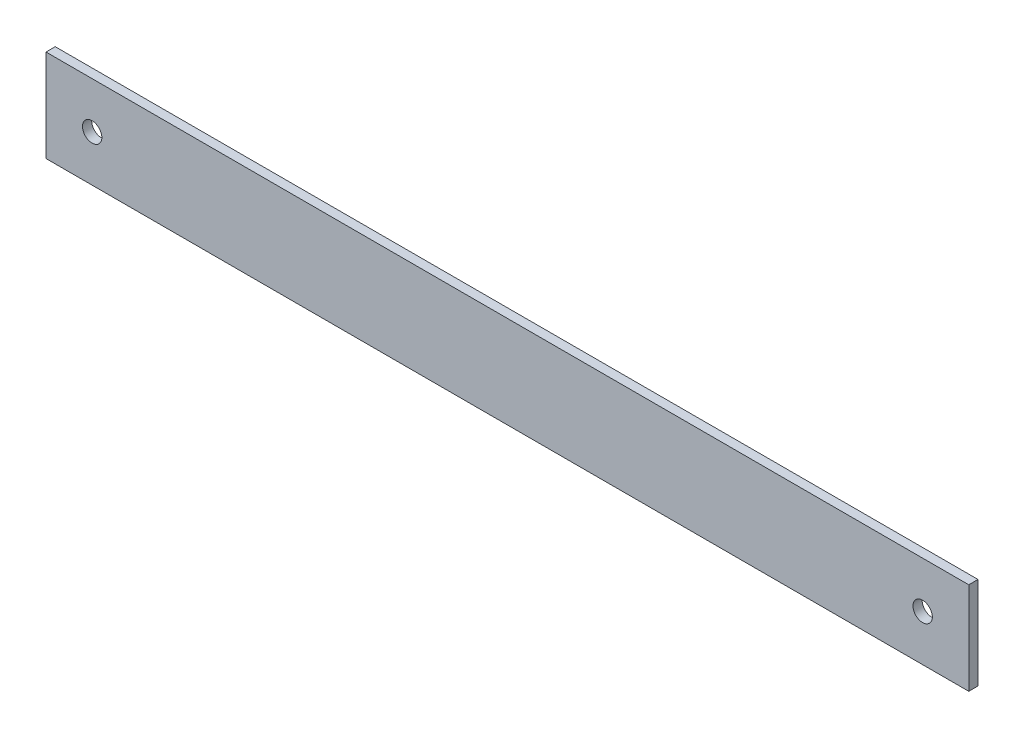
from build123d import *

# Parameters (mm, degrees)
SKETCH_1_W          = 1000
SKETCH_1_H          = 100
EXTRUDE_1_DEPTH     = 5
HOLE_WIZARD_M24_1_D = 21


with BuildPart() as part:
    # 草图1 → 凸台-拉伸1 (new body, symmetric)
    with BuildSketch(Plane.XY):
        Rectangle(SKETCH_1_W, SKETCH_1_H)
    extrude(amount=EXTRUDE_1_DEPTH, both=True)

    # M24 螺纹孔1 (through all)
    with Locations(Plane.XY.offset(5)):
        with Locations((-450, 0), (450, 0)):
            Hole(HOLE_WIZARD_M24_1_D / 2)


solid = part.part
